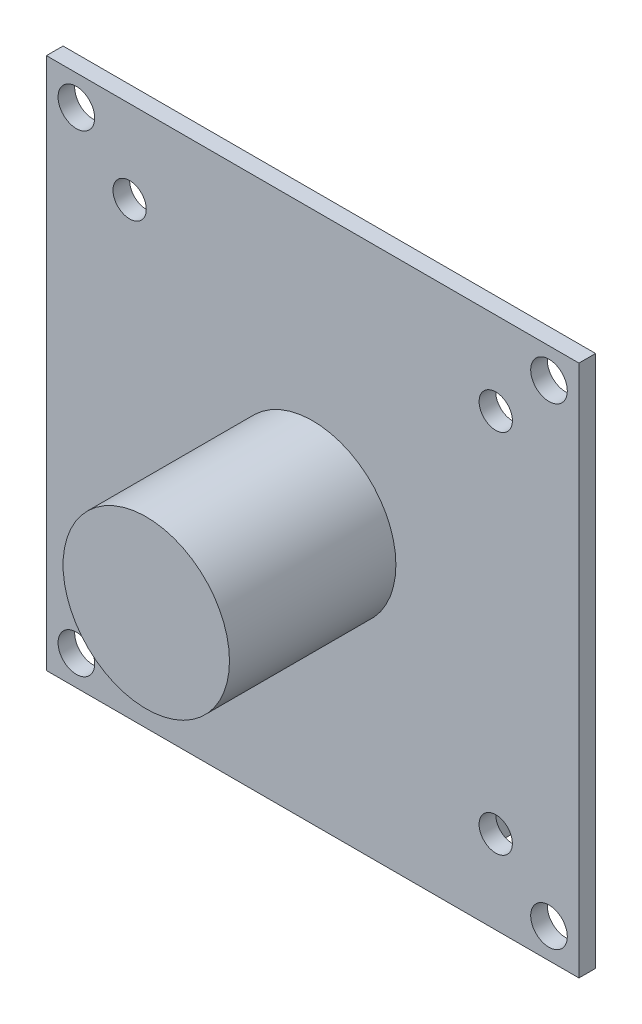
from build123d import *

# Parameters (mm, degrees)
SKETCH1_W           = 32
SKETCH1_H           = 32
BOSS_EXTRUDE1_DEPTH = 1
SKETCH2_R           = 1
CUT_EXTRUDE1_DEPTH  = 1
SKETCH3_R           = 5
BOSS_EXTRUDE2_DEPTH = 10
SKETCH4_W           = 10
SKETCH4_H           = 4.5
BOSS_EXTRUDE3_DEPTH = 6
SKETCH5_R           = 1.1
CUT_EXTRUDE2_DEPTH  = 2


with BuildPart() as part:
    # Sketch1 → Boss-Extrude1 (new body)
    with BuildSketch(Plane.XY):
        Rectangle(SKETCH1_W, SKETCH1_H)
    extrude(amount=BOSS_EXTRUDE1_DEPTH)

    # Sketch2 → Cut-Extrude1 (cut)
    with BuildSketch(Plane.XY.offset(1)):
        with Locations((-11, 11)):
            Circle(SKETCH2_R)
        with Locations((11, 11)):
            Circle(SKETCH2_R)
        with Locations((11, -11)):
            Circle(SKETCH2_R)
        with Locations((-11, -11)):
            Circle(SKETCH2_R)
    extrude(amount=-CUT_EXTRUDE1_DEPTH, mode=Mode.SUBTRACT)

    # Sketch3 → Boss-Extrude2 (add)
    with BuildSketch(Plane.XY.offset(1)):
        Circle(SKETCH3_R)
    extrude(amount=BOSS_EXTRUDE2_DEPTH)

    # Sketch4 → Boss-Extrude3 (add)
    with BuildSketch(Plane(origin=(0, 0, 0), x_dir=(-1, 0, 0), z_dir=(0, 0, -1))):
        with Locations((-3, -12.25)):
            Rectangle(SKETCH4_W, SKETCH4_H)
    extrude(amount=BOSS_EXTRUDE3_DEPTH)

    # Sketch5 → Cut-Extrude2 (cut)
    with BuildSketch(Plane.XY.offset(1)):
        with Locations((-14.2, 14.2)):
            Circle(SKETCH5_R)
        with Locations((14.2, 14.2)):
            Circle(SKETCH5_R)
        with Locations((14.2, -14.2)):
            Circle(SKETCH5_R)
        with Locations((-14.2, -14.2)):
            Circle(SKETCH5_R)
    extrude(amount=-CUT_EXTRUDE2_DEPTH, mode=Mode.SUBTRACT)


solid = part.part
